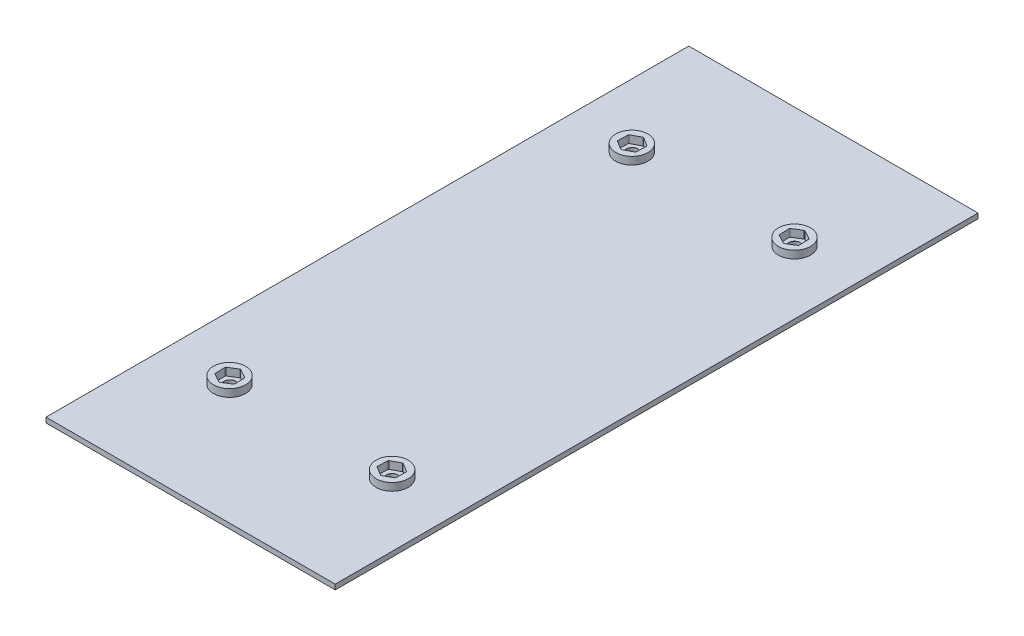
from build123d import *

# Parameters (mm, degrees)
SKETCH1_W                     = 114.3
SKETCH1_H                     = 254
BOSS_EXTRUDE1_DEPTH           = 2.000000064
M4_CLEARANCE_HOLE1_AT_2_COUNT = 2
M4_CLEARANCE_HOLE1_AT_2_PITCH = 64.13133097
M4_CLEARANCE_HOLE1_AT_3_COUNT = 2
M4_CLEARANCE_HOLE1_AT_3_PITCH = 171.44126128
M4_CLEARANCE_HOLE1_AT_4_COUNT = 2
M4_CLEARANCE_HOLE1_AT_4_PITCH = 158.994586252
SKETCH8_R                     = 6.35
BOSS_EXTRUDE3_DEPTH           = 3


with BuildPart() as part:
    # Sketch1 → Boss-Extrude1 (new body)
    with BuildSketch(Plane(origin=(0, 0, 0), x_dir=(1, 0, 0), z_dir=(0, 1, 0))):
        with Locations((57.15, 127)):
            Rectangle(SKETCH1_W, SKETCH1_H)
    extrude(amount=BOSS_EXTRUDE1_DEPTH)

    # Sketch6 → M4 Clearance Hole1 (revolve, cut)
    with BuildSketch(Plane(origin=(25.146, 2.000000064, -206.502), x_dir=(0, 0, 1), z_dir=(1, 0, 0))):
        Polygon((0, 0), (0, 2.000000064), (2.25, 2.000000064), (2.25, 0.025), (2.275, 0), align=None)
    m4_clearance_hole1 = revolve(axis=Axis((25.146, 8.350000064, -206.502), (0, -1, 0)), mode=Mode.SUBTRACT)

    # M4 Clearance Hole1 at 2: M4 Clearance Hole1 ×2
    with Locations(*[(i * M4_CLEARANCE_HOLE1_AT_2_PITCH, 0, 0) for i in range(1, M4_CLEARANCE_HOLE1_AT_2_COUNT)]):
        add(m4_clearance_hole1, mode=Mode.SUBTRACT)

    # M4 Clearance Hole1 at 3: M4 Clearance Hole1 ×2
    with Locations(*[Vector(0.37407174, 0, 0.92739977) * (i * M4_CLEARANCE_HOLE1_AT_3_PITCH) for i in range(1, M4_CLEARANCE_HOLE1_AT_3_COUNT)]):
        add(m4_clearance_hole1, mode=Mode.SUBTRACT)

    # M4 Clearance Hole1 at 4: M4 Clearance Hole1 ×2
    with Locations(*[(0, 0, i * M4_CLEARANCE_HOLE1_AT_4_PITCH) for i in range(1, M4_CLEARANCE_HOLE1_AT_4_COUNT)]):
        add(m4_clearance_hole1, mode=Mode.SUBTRACT)

    # Sketch8 → Boss-Extrude3 (add)
    with BuildSketch(Plane(origin=(0, 2.000000064, 0), x_dir=(1, 0, 0), z_dir=(0, 1, 0))):
        with Locations((89.27733097, 47.507413748)):
            Circle(SKETCH8_R)
        with BuildLine():
            ThreePointArc((89.228972354, 43.291716477), (89.012687116, 43.241374316), (88.800207525, 43.305919345))
            Line((88.800207525, 43.305919345), (85.540585246, 45.334637149))
            ThreePointArc((85.540585246, 45.334637149), (85.388845037, 45.496774579), (85.338502876, 45.713059817))
            Line((85.338502876, 45.713059817), (85.465612892, 49.55033442))
            ThreePointArc((85.465612892, 49.55033442), (85.53015792, 49.762814011), (85.692295351, 49.91455422))
            Line((85.692295351, 49.91455422), (89.079027646, 51.723111019))
            ThreePointArc((89.079027646, 51.723111019), (89.295312884, 51.77345318), (89.507792475, 51.708908151))
            Line((89.507792475, 51.708908151), (92.767414754, 49.680190347))
            ThreePointArc((92.767414754, 49.680190347), (92.919154963, 49.518052917), (92.969497124, 49.301767679))
            Line((92.969497124, 49.301767679), (92.842387108, 45.464493076))
            ThreePointArc((92.842387108, 45.464493076), (92.77784208, 45.252013485), (92.615704649, 45.100273276))
            Line((92.615704649, 45.100273276), (89.228972354, 43.291716477))
        make_face(mode=Mode.SUBTRACT)
        with Locations((25.02266903, 47.507413748)):
            Circle(SKETCH8_R)
        with BuildLine():
            Line((28.759414754, 45.334637149), (25.499792475, 43.305919345))
            ThreePointArc((25.499792475, 43.305919345), (25.287312884, 43.241374316), (25.071027646, 43.291716477))
            Line((25.071027646, 43.291716477), (21.684295351, 45.100273276))
            ThreePointArc((21.684295351, 45.100273276), (21.52215792, 45.252013485), (21.457612892, 45.464493076))
            Line((21.457612892, 45.464493076), (21.330502876, 49.301767679))
            ThreePointArc((21.330502876, 49.301767679), (21.380845037, 49.518052917), (21.532585246, 49.680190347))
            Line((21.532585246, 49.680190347), (24.792207525, 51.708908151))
            ThreePointArc((24.792207525, 51.708908151), (25.004687116, 51.77345318), (25.220972354, 51.723111019))
            Line((25.220972354, 51.723111019), (28.607704649, 49.91455422))
            ThreePointArc((28.607704649, 49.91455422), (28.76984208, 49.762814011), (28.834387108, 49.55033442))
            Line((28.834387108, 49.55033442), (28.961497124, 45.713059817))
            ThreePointArc((28.961497124, 45.713059817), (28.911154963, 45.496774579), (28.759414754, 45.334637149))
        make_face(mode=Mode.SUBTRACT)
        with Locations((89.27733097, 206.492586252)):
            Circle(SKETCH8_R)
        with BuildLine():
            Line((89.228972354, 210.708283523), (92.615704649, 208.899726724))
            ThreePointArc((92.615704649, 208.899726724), (92.77784208, 208.747986515), (92.842387108, 208.535506924))
            Line((92.842387108, 208.535506924), (92.969497124, 204.698232321))
            ThreePointArc((92.969497124, 204.698232321), (92.919154963, 204.481947083), (92.767414754, 204.319809653))
            Line((92.767414754, 204.319809653), (89.507792475, 202.291091849))
            ThreePointArc((89.507792475, 202.291091849), (89.295312884, 202.22654682), (89.079027646, 202.276888981))
            Line((89.079027646, 202.276888981), (85.692295351, 204.08544578))
            ThreePointArc((85.692295351, 204.08544578), (85.53015792, 204.237185989), (85.465612892, 204.44966558))
            Line((85.465612892, 204.44966558), (85.338502876, 208.286940183))
            ThreePointArc((85.338502876, 208.286940183), (85.388845037, 208.503225421), (85.540585246, 208.665362851))
            Line((85.540585246, 208.665362851), (88.800207525, 210.694080655))
            ThreePointArc((88.800207525, 210.694080655), (89.012687116, 210.758625684), (89.228972354, 210.708283523))
        make_face(mode=Mode.SUBTRACT)
        with Locations((25.02266903, 206.492586252)):
            Circle(SKETCH8_R)
        with BuildLine():
            ThreePointArc((25.071027646, 210.708283523), (25.287312884, 210.758625684), (25.499792475, 210.694080655))
            Line((25.499792475, 210.694080655), (28.759414754, 208.665362851))
            ThreePointArc((28.759414754, 208.665362851), (28.911154963, 208.503225421), (28.961497124, 208.286940183))
            Line((28.961497124, 208.286940183), (28.834387108, 204.44966558))
            ThreePointArc((28.834387108, 204.44966558), (28.76984208, 204.237185989), (28.607704649, 204.08544578))
            Line((28.607704649, 204.08544578), (25.220972354, 202.276888981))
            ThreePointArc((25.220972354, 202.276888981), (25.004687116, 202.22654682), (24.792207525, 202.291091849))
            Line((24.792207525, 202.291091849), (21.532585246, 204.319809653))
            ThreePointArc((21.532585246, 204.319809653), (21.380845037, 204.481947083), (21.330502876, 204.698232321))
            Line((21.330502876, 204.698232321), (21.457612892, 208.535506924))
            ThreePointArc((21.457612892, 208.535506924), (21.52215792, 208.747986515), (21.684295351, 208.899726724))
            Line((21.684295351, 208.899726724), (25.071027646, 210.708283523))
        make_face(mode=Mode.SUBTRACT)
    extrude(amount=BOSS_EXTRUDE3_DEPTH)


solid = part.part
